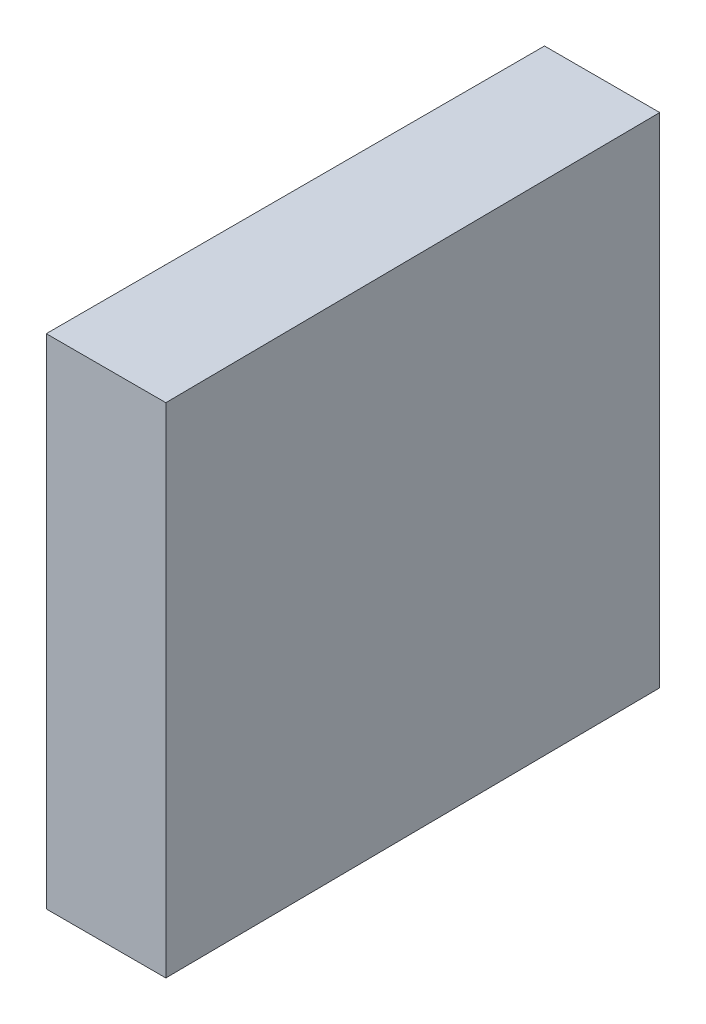
from build123d import *

# Parameters (mm, degrees)
EXTRUDE_1_DEPTH = 12.5


with BuildPart() as part:
    # 草图1 → 凸台-拉伸1 (new body)
    with BuildSketch(Plane(origin=(0, 0, 0), x_dir=(1, 0, 0), z_dir=(0, 1, 0))):
        Polygon((0, 6.25), (0, -6.25), (3, -6.25), (2.890914153, 6.25), align=None)
    extrude(amount=EXTRUDE_1_DEPTH)


solid = part.part
